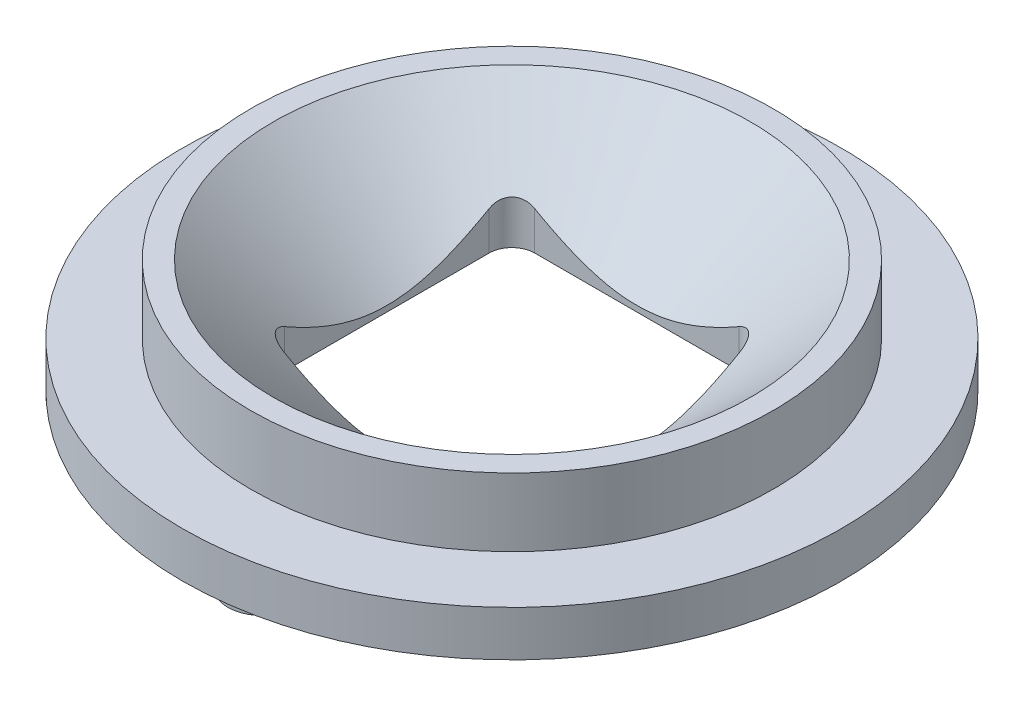
from build123d import *

# Parameters (mm, degrees)
SKETCH1_R         = 14.5
BODY_DEPTH        = 2
SKETCH2_R         = 1.5
FIXHOLES_DEPTH    = 2
SKETCH3_R         = 11.5
BODY2_DEPTH       = 3
SKETCH5_W         = 11
SKETCH5_H         = 11
WINDOW_HOLE_DEPTH = 12
SKETCH7_W         = 13
SKETCH7_H         = 13
WINDOW_DEPTH      = 0.25
WINDOW_FILLET_R   = 1


with BuildPart() as part:
    # Sketch1 → Body (new body)
    with BuildSketch(Plane(origin=(0, 0, 0), x_dir=(1, 0, 0), z_dir=(0, 1, 0))):
        Circle(SKETCH1_R)
    extrude(amount=BODY_DEPTH)

    # Sketch2 → FixHoles (add)
    with BuildSketch(Plane.XZ):
        with Locations((0, 11)):
            Circle(SKETCH2_R)
        with Locations((0, -11)):
            Circle(SKETCH2_R)
    extrude(amount=FIXHOLES_DEPTH)

    # Sketch3 → Body2 (add)
    with BuildSketch(Plane(origin=(0, 2, 0), x_dir=(1, 0, 0), z_dir=(0, 1, 0))):
        Circle(SKETCH3_R)
    extrude(amount=BODY2_DEPTH)

    # Sketch5 → Window_hole (cut)
    with BuildSketch(Plane.XZ):
        Rectangle(SKETCH5_W, SKETCH5_H)
    extrude(amount=-WINDOW_HOLE_DEPTH, mode=Mode.SUBTRACT)

    # Sketch6 → Objective_cut (revolve, cut)
    with BuildSketch(Plane.XY):
        Polygon((-5.5, 5), (-10.5, 5), (-5.5, 0.5), align=None)
    revolve(axis=Axis((0, 7.375311512, 0), (0, -1, 0)), mode=Mode.SUBTRACT)

    # Sketch7 → Window (cut)
    with BuildSketch(Plane.XZ):
        Rectangle(SKETCH7_W, SKETCH7_H)
    extrude(amount=-WINDOW_DEPTH, mode=Mode.SUBTRACT)

    # Window_Fillet
    window_fillet_edges = [part.edges().sort_by_distance(p)[0] for p in [
        (-5.5, 1.400178567, 5.5),
        (5.5, 1.400178567, 5.5),
        (5.5, 1.400178567, -5.5),
        (-5.5, 1.400178567, -5.5),
    ]]
    fillet(window_fillet_edges, radius=WINDOW_FILLET_R)


solid = part.part
